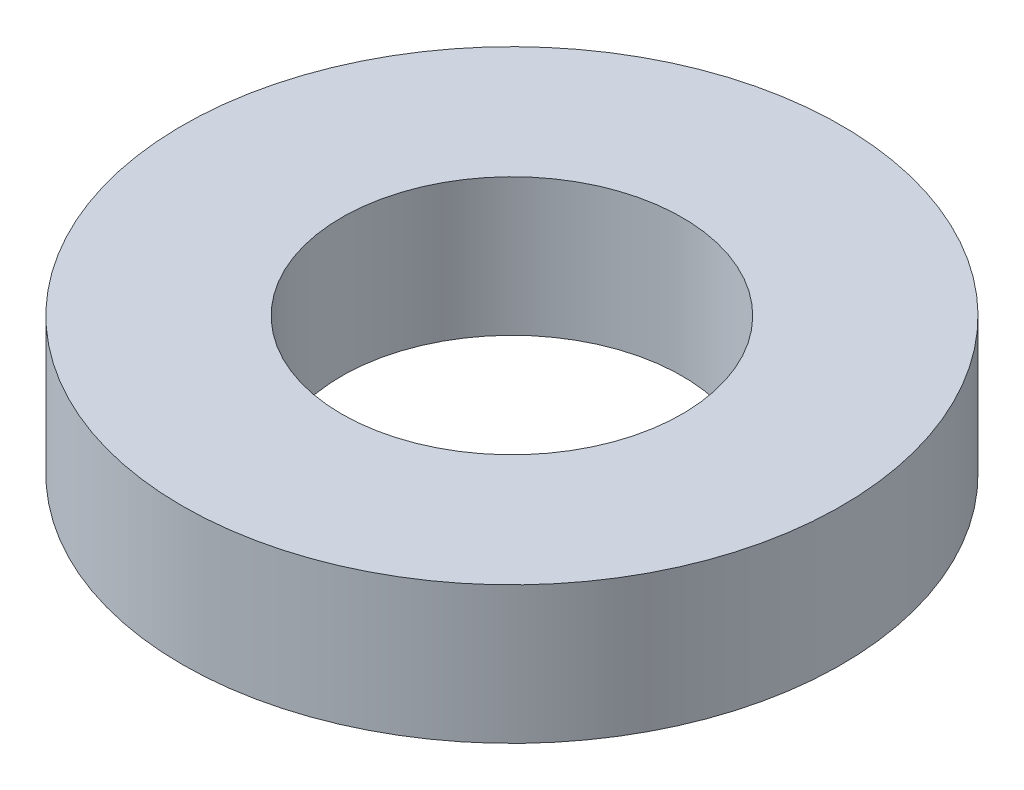
from build123d import *

# Parameters (mm, degrees)
SKETCH1_R           = 3
SKETCH1_R_2         = 1.55
BOSS_EXTRUDE1_DEPTH = 1.25


with BuildPart() as part:
    # Sketch1 → Boss-Extrude1 (new body)
    with BuildSketch(Plane(origin=(0, 0, 0), x_dir=(1, 0, 0), z_dir=(0, 1, 0))):
        Circle(SKETCH1_R)
        Circle(SKETCH1_R_2, mode=Mode.SUBTRACT)
    extrude(amount=BOSS_EXTRUDE1_DEPTH)


solid = part.part
